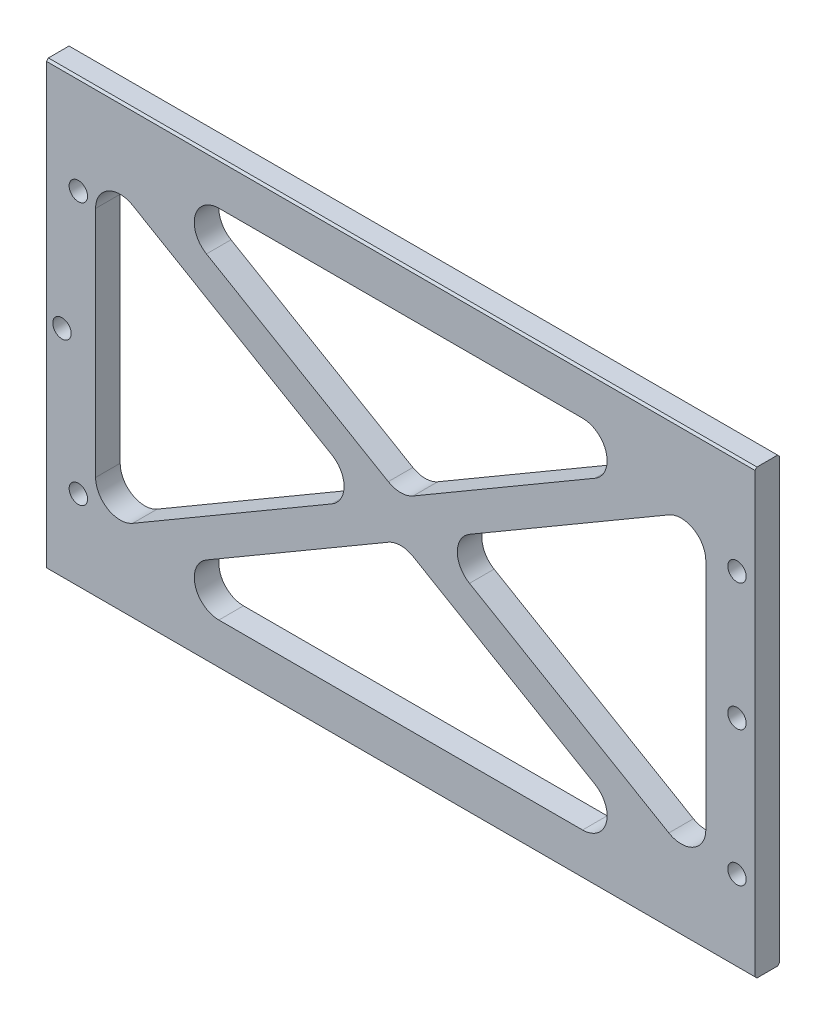
from build123d import *

# Parameters (mm, degrees)
SKETCH1_W                       = 274.5232
SKETCH1_H                       = 171.45
BOSS_EXTRUDE1_DEPTH             = 9.525
F_9_32_0_28125_DIAMETER_HOLE1_D = 7.14375
CHAMFER1_SIZE                   = 0.762
CUT_EXTRUDE1_DEPTH              = 10.525


with BuildPart() as part:
    # Sketch1 → Boss-Extrude1 (new body)
    with BuildSketch(Plane.XY):
        with Locations((137.2616, 85.725)):
            Rectangle(SKETCH1_W, SKETCH1_H)
    extrude(amount=BOSS_EXTRUDE1_DEPTH)

    # 9/32 (0.28125) Diameter Hole1 (through all)
    with Locations(Plane.XY.offset(9.525)):
        with Locations((6.0198, 84.1248), (12.3698, 133.35), (12.3698, 31.75), (267.5382, 133.35), (267.5382, 84.1248), (267.5382, 31.75)):
            Hole(F_9_32_0_28125_DIAMETER_HOLE1_D / 2)

    # Chamfer1
    chamfer1_edges = [part.edges().sort_by_distance(p)[0] for p in [
        (137.2616, 171.45, 9.525),
        (137.2616, 171.45, 0),
        (137.2616, 0, 0),
        (137.2616, 0, 9.525),
    ]]
    chamfer(chamfer1_edges, length=CHAMFER1_SIZE)

    # Sketch6 → Cut-Extrude1 (cut, through all)
    with BuildSketch(Plane.XY.offset(9.525)):
        with BuildLine():
            Line((33.381181438, 139.082261479), (110.606344338, 93.948517799))
            ThreePointArc((110.606344338, 93.948517799), (115.325162901, 85.725), (110.606344338, 77.501482201))
            Line((110.606344338, 77.501482201), (33.381181438, 32.367738521))
            ThreePointArc((33.381181438, 32.367738521), (23.834391031, 32.329764227), (19.05, 40.591256319))
            Line((19.05, 40.591256319), (19.05, 130.858743681))
            ThreePointArc((19.05, 130.858743681), (23.834391031, 139.120235773), (33.381181438, 139.082261479))
        make_face()
        with BuildLine():
            Line((62.002810809, 137.064482201), (132.455418562, 95.888914284))
            ThreePointArc((132.455418562, 95.888914284), (137.2616, 94.587432082), (142.067781438, 95.888914284))
            Line((142.067781438, 95.888914284), (212.520389191, 137.064482201))
            ThreePointArc((212.520389191, 137.064482201), (216.908081584, 147.777640332), (207.714207753, 154.813))
            Line((207.714207753, 154.813), (66.808992247, 154.813))
            ThreePointArc((66.808992247, 154.813), (57.615118416, 147.777640332), (62.002810809, 137.064482201))
        make_face()
        with BuildLine():
            Line((241.142018562, 139.082261479), (163.916855662, 93.948517799))
            ThreePointArc((163.916855662, 93.948517799), (159.198037099, 85.725), (163.916855662, 77.501482201))
            Line((163.916855662, 77.501482201), (241.142018562, 32.367738521))
            ThreePointArc((241.142018562, 32.367738521), (250.688808969, 32.329764227), (255.4732, 40.591256319))
            Line((255.4732, 40.591256319), (255.4732, 130.858743681))
            ThreePointArc((255.4732, 130.858743681), (250.688808969, 139.120235773), (241.142018562, 139.082261479))
        make_face()
        with BuildLine():
            Line((66.808992247, 16.637), (207.714207753, 16.637))
            ThreePointArc((207.714207753, 16.637), (216.908081584, 23.672359668), (212.520389191, 34.385517799))
            Line((212.520389191, 34.385517799), (142.067781438, 75.561085716))
            ThreePointArc((142.067781438, 75.561085716), (137.2616, 76.862567918), (132.455418562, 75.561085716))
            Line((132.455418562, 75.561085716), (62.002810809, 34.385517799))
            ThreePointArc((62.002810809, 34.385517799), (57.615118416, 23.672359668), (66.808992247, 16.637))
        make_face()
    extrude(amount=-CUT_EXTRUDE1_DEPTH, mode=Mode.SUBTRACT)


solid = part.part
